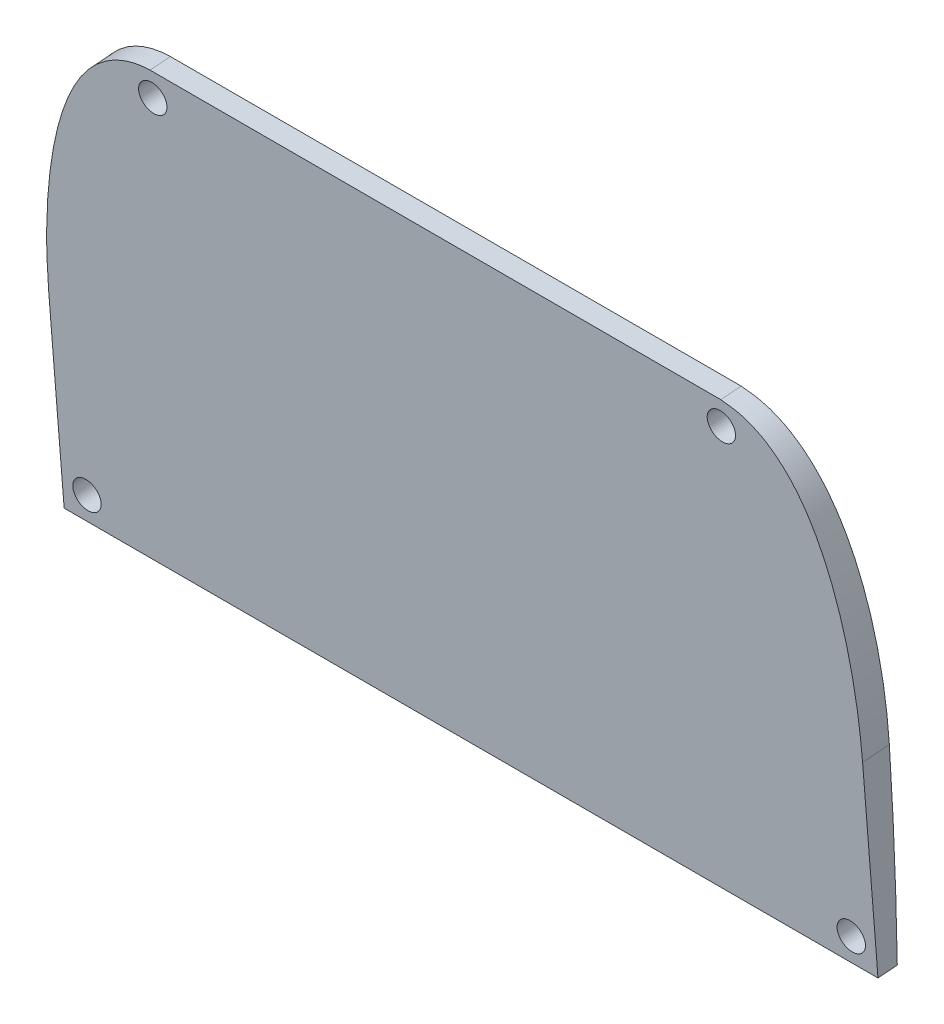
from build123d import *

# Parameters (mm, degrees)
BOSS_EXTRUDE1_DEPTH     = 10
CUT_EXTRUDE1_DEPTH      = 29.7500001
CUT_EXTRUDE1_DEPTH_BACK = 29.7500001
SKETCH3_R               = 1
CUT_EXTRUDE2_DEPTH      = 4.923231052
CUT_EXTRUDE3_DEPTH      = 1.5
CUT_EXTRUDE3_DEPTH_BACK = 1.5


with BuildPart() as part:
    # Sketch1 → Boss-Extrude1 (new body)
    with BuildSketch(Plane(origin=(0, 1.945661651, -24.597655762), x_dir=(-1, 0, 0), z_dir=(0, 0.078853178, -0.99688624))):
        with BuildLine():
            Line((20.118741527, 38.927510312), (-20.205875274, 38.927510312))
            add(Edge.make_bspline(
                [(-20.205875274, 38.927510312), (-20.634098963, 38.892508679), (-21.245835645, 38.778527706), (-21.793411937, 38.641980138), (-22.83466937, 38.198372766), (-23.803353052, 37.478891051), (-24.412556983, 36.884589854), (-24.877490419, 36.344634644), (-25.274800342, 35.805277697), (-25.669505912, 35.18759196), (-25.991077332, 34.611835039), (-26.32458833, 33.935091847), (-26.581827221, 33.349429206), (-26.836336049, 32.707670323), (-27.074080176, 32.039745124), (-27.305049825, 31.313313179), (-27.481649368, 30.696229384), (-27.655403582, 30.02827487), (-27.816800686, 29.340274847), (-27.971090091, 28.607665746), (-28.095711792, 27.948768651), (-28.241597872, 27.08964074), (-28.41706896, 25.841083684), (-28.566039373, 24.442848024), (-28.660522397, 23.195980042), (-28.698123211, 22.438130684), (-28.713170303, 22.033583315), (-28.72027007, 21.807636048), (-28.725707261, 21.608687715), (-28.728334052, 21.498509224), (-28.732226056, 21.320526835), (-28.742152393, 20.794672691), (-28.75, 20.202294151)],
                knots=[0.000338989, 0.000338989, 0.000338989, 0.039386118, 0.055004969, 0.094052098, 0.156527504, 0.203384058, 0.234621761, 0.265859464, 0.297097167, 0.32833487, 0.359572573, 0.390810276, 0.422047979, 0.453285682, 0.484523385, 0.515761088, 0.546998791, 0.578236494, 0.609474197, 0.640711899, 0.671949602, 0.718806157, 0.781281563, 0.843756969, 0.890613523, 0.9140418, 0.925755939, 0.933565364, 0.94137479, 0.949184216, 0.960898355, 0.999945483, 0.999945483, 0.999945483], degree=2))
            Line((-28.75, 20.202294151), (-28.75, 6.427510312))
            Line((-28.75, 6.427510312), (28.75, 6.427510312))
            Line((28.75, 6.427510312), (28.75, 20.202249554))
            add(Edge.make_bspline(
                [(28.75, 20.202249554), (28.742136693, 20.796879453), (28.732153075, 21.324936339), (28.728235159, 21.503651904), (28.725584002, 21.614499101), (28.720117851, 21.813723731), (28.712966508, 22.040249775), (28.697791077, 22.446118641), (28.659754195, 23.208534642), (28.564499372, 24.459675982), (28.41440803, 25.863683892), (28.236422496, 27.123346764), (28.088268606, 27.990052525), (27.961749799, 28.654446766), (27.804153919, 29.396998515), (27.639250072, 30.093405593), (27.461661247, 30.768996368), (27.280351534, 31.39492368), (27.047223746, 32.118771853), (26.806541555, 32.786223535), (26.548675473, 33.427949309), (26.320925204, 33.938978857), (26.120412213, 34.352471329), (25.92443028, 34.732794288), (25.622678502, 35.265443849), (25.234423765, 35.863259987), (24.830722495, 36.402891666), (24.353019395, 36.948050348), (23.75151585, 37.525160308), (22.759896414, 38.235388353), (21.166231977, 38.900698382), (20.118741527, 38.927510312)],
                knots=[5.4217e-05, 5.4217e-05, 5.4217e-05, 0.039105236, 0.050820541, 0.058630745, 0.066440949, 0.074251153, 0.085966458, 0.109397069, 0.156258292, 0.218739922, 0.281221552, 0.328082774, 0.359323589, 0.390564404, 0.421805219, 0.453046034, 0.484286849, 0.515527664, 0.546768479, 0.578009294, 0.609250109, 0.63268072, 0.648301127, 0.671731738, 0.702972553, 0.734213368, 0.765454183, 0.796694998, 0.843556221, 0.90603785, 0.999760295, 0.999760295, 0.999760295], degree=2))
        make_face()
    extrude(amount=BOSS_EXTRUDE1_DEPTH)

    # Sketch2 → Cut-Extrude1 (cut, two sides)
    with BuildSketch(Plane(origin=(0, 0, 0), x_dir=(0, 0, -1), z_dir=(1, 0, 0))) as cut_extrude1_sk:
        with BuildLine():
            add(Edge.make_bspline(
                [(25.5, 3.2), (25.5, 6.804109149), (25.372537051, 14.023285861), (24.790435794, 24.776005778), (23.772909366, 35.484880024), (22.745170912, 42.556468877), (22.107794841, 46.073141759)],
                knots=[0, 0, 0, 0, 0.25, 0.5, 0.75, 1, 1, 1, 1], degree=3))
            Line((22.107794841, 46.073141759), (43.259032881, 46.073141759))
            Line((43.259032881, 46.073141759), (43.259032881, 3.2))
            Line((43.259032881, 3.2), (25.5, 3.2))
        make_face()
    extrude(amount=CUT_EXTRUDE1_DEPTH, mode=Mode.SUBTRACT)
    extrude(cut_extrude1_sk.sketch, amount=-CUT_EXTRUDE1_DEPTH_BACK, mode=Mode.SUBTRACT)

    # Sketch3 → Cut-Extrude2 (cut, through all)
    with BuildSketch(Plane(origin=(0, 1.945661651, -24.597655762), x_dir=(1, 0, 0), z_dir=(0, -0.078853178, 0.99688624))):
        with Locations((-20.062840726, 37.177510312)):
            Circle(SKETCH3_R)
        with Locations((-27, 8.177510312)):
            Circle(SKETCH3_R)
        with Locations((20.109740551, 37.177510312)):
            Circle(SKETCH3_R)
        with Locations((27, 8.177510312)):
            Circle(SKETCH3_R)
    extrude(amount=-CUT_EXTRUDE2_DEPTH, mode=Mode.SUBTRACT)

    # Sketch6 → Cut-Extrude3 (cut, two sides)
    with BuildSketch(Plane(origin=(0, 2.095157837, -26.487632732), x_dir=(1, 0, 0), z_dir=(0, -0.078853178, 0.99688624))) as cut_extrude3_sk:
        with BuildLine():
            Line((7.641783437, 31.566440312), (7.641783437, 31.529400312))
            add(Edge.make_bspline(
                [(7.641783437, 31.529400312), (7.641783437, 23.259600312), (7.641783437, 17.797520312), (0.038703437, 13.797040312)],
                knots=[0.125, 0.125, 0.125, 0.125, 0.25, 0.25, 0.25, 0.25], degree=3))
            Line((0.038703437, 13.797040312), (0.021783437, 13.787520312))
            Line((0.021783437, 13.787520312), (0.004863437, 13.797040312))
            add(Edge.make_bspline(
                [(0.004863437, 13.797040312), (-7.598216563, 17.780600312), (-7.598216563, 23.251120312), (-7.598216563, 31.531520312)],
                knots=[0.5, 0.5, 0.5, 0.5, 0.625, 0.625, 0.625, 0.625], degree=3))
            Line((-7.598216563, 31.531520312), (-7.598216563, 31.568560312))
            Line((-7.598216563, 31.568560312), (7.641783437, 31.566440312))
        make_face()
        with BuildLine():
            Line((-7.028816563, 30.931440312), (-7.028816563, 30.956840312))
            Line((-7.028816563, 30.956840312), (7.091463437, 30.954720312))
            Line((7.091463437, 30.954720312), (7.091463437, 30.929320312))
            add(Edge.make_bspline(
                [(7.091463437, 30.929320312), (7.091463437, 30.702840312), (7.091463437, 30.476360312), (7.092503437, 30.250920312)],
                knots=[0.25, 0.25, 0.25, 0.25, 0.333333333, 0.333333333, 0.333333333, 0.333333333], degree=3))
            add(Edge.make_bspline(
                [(7.092503437, 30.250920312), (7.097783437, 27.110880312), (7.102023437, 24.145400312), (6.220423437, 21.426560312)],
                knots=[0.333333333, 0.333333333, 0.333333333, 0.333333333, 0.416666667, 0.416666667, 0.416666667, 0.416666667], degree=3))
            add(Edge.make_bspline(
                [(6.220423437, 21.426560312), (5.746303437, 19.963960312), (5.059423437, 18.717240312), (4.120703437, 17.614440312)],
                knots=[0.416666667, 0.416666667, 0.416666667, 0.416666667, 0.5, 0.5, 0.5, 0.5], degree=3))
            add(Edge.make_bspline(
                [(4.120703437, 17.614440312), (3.069783437, 16.379360312), (1.730983437, 15.352800312), (0.028143437, 14.476480312)],
                knots=[0.5, 0.5, 0.5, 0.5, 0.583333333, 0.583333333, 0.583333333, 0.583333333], degree=3))
            Line((0.028143437, 14.476480312), (0.016503437, 14.470120312))
            Line((0.016503437, 14.470120312), (0.004863437, 14.476480312))
            add(Edge.make_bspline(
                [(0.004863437, 14.476480312), (-7.042576563, 18.137240312), (-7.036216563, 24.066040312), (-7.028816563, 30.340880312)],
                knots=[0.75, 0.75, 0.75, 0.75, 0.833333333, 0.833333333, 0.833333333, 0.833333333], degree=3))
            add(Edge.make_bspline(
                [(-7.028816563, 30.340880312), (-7.028816563, 30.537760312), (-7.028816563, 30.734600312), (-7.028816563, 30.931440312)],
                knots=[0.833333333, 0.833333333, 0.833333333, 0.833333333, 1, 1, 1, 1], degree=3))
        make_face(mode=Mode.SUBTRACT)
        Polygon((4.152463437, 26.637800312), (-0.047016563, 27.948000312), (-4.263416563, 26.637800312), align=None)
        Polygon((-2.204936563, 27.364880312), (-2.204936563, 28.448600312), (2.069663437, 28.448600312), (2.069663437, 27.375440312), (-0.047016563, 28.035840312), align=None)
        with BuildLine():
            Line((0.480023437, 29.278320312), (-0.586776563, 29.278320312))
            add(Edge.make_bspline(
                [(-0.586776563, 29.278320312), (-0.592056563, 29.644520312), (-0.297856563, 29.923920312), (-0.045976563, 30.147200312)],
                knots=[0.25, 0.25, 0.25, 0.25, 0.5, 0.5, 0.5, 0.5], degree=3))
            add(Edge.make_bspline(
                [(-0.045976563, 30.147200312), (0.202743437, 29.919680312), (0.480023437, 29.655120312), (0.480023437, 29.278320312)],
                knots=[0.5, 0.5, 0.5, 0.5, 1, 1, 1, 1], degree=3))
        make_face()
        with BuildLine():
            Line((-0.565576563, 29.241280312), (0.445103437, 29.241280312))
            add(Edge.make_bspline(
                [(0.445103437, 29.241280312), (0.955223437, 29.126960312), (1.370103437, 28.848640312), (1.569063437, 28.486680312)],
                knots=[0.2, 0.2, 0.2, 0.2, 0.4, 0.4, 0.4, 0.4], degree=3))
            Line((1.569063437, 28.486680312), (-1.689536563, 28.486720312))
            add(Edge.make_bspline(
                [(-1.689536563, 28.486720312), (-1.490576563, 28.848640312), (-1.075696563, 29.128040312), (-0.565576563, 29.241280312)],
                knots=[0.6, 0.6, 0.6, 0.6, 1, 1, 1, 1], degree=3))
        make_face()
        with BuildLine():
            Line((2.483463437, 20.711120312), (2.483463437, 19.465480312))
            add(Edge.make_bspline(
                [(2.483463437, 19.465480312), (2.483463437, 19.370240312), (2.553303437, 19.338480312), (2.643263437, 19.333200312)],
                knots=[0.117647059, 0.117647059, 0.117647059, 0.117647059, 0.176470588, 0.176470588, 0.176470588, 0.176470588], degree=3))
            Line((2.643263437, 19.333200312), (2.846463437, 19.324720312))
            Line((2.846463437, 19.324720312), (2.846463437, 19.219960312))
            add(Edge.make_bspline(
                [(2.846463437, 19.219960312), (2.517303437, 19.223120312), (2.395623437, 19.228440312), (2.274943437, 19.228440312)],
                knots=[0.294117647, 0.294117647, 0.294117647, 0.294117647, 0.352941176, 0.352941176, 0.352941176, 0.352941176], degree=3))
            add(Edge.make_bspline(
                [(2.274943437, 19.228440312), (2.151103437, 19.228440312), (2.032583437, 19.223160312), (1.776463437, 19.219960312)],
                knots=[0.352941176, 0.352941176, 0.352941176, 0.352941176, 0.411764706, 0.411764706, 0.411764706, 0.411764706], degree=3))
            Line((1.776463437, 19.219960312), (1.776463437, 19.324720312))
            Line((1.776463437, 19.324720312), (1.952143437, 19.333200312))
            add(Edge.make_bspline(
                [(1.952143437, 19.333200312), (2.041063437, 19.338480312), (2.111943437, 19.369200312), (2.111943437, 19.465480312)],
                knots=[0.529411765, 0.529411765, 0.529411765, 0.529411765, 0.588235294, 0.588235294, 0.588235294, 0.588235294], degree=3))
            Line((2.111943437, 19.465480312), (2.111943437, 20.371400312))
            add(Edge.make_bspline(
                [(2.111943437, 20.371400312), (2.111943437, 20.707960312), (2.092903437, 20.949240312), (2.083383437, 21.084720312)],
                knots=[0.647058824, 0.647058824, 0.647058824, 0.647058824, 0.705882353, 0.705882353, 0.705882353, 0.705882353], degree=3))
            Line((2.083383437, 21.084720312), (2.118303437, 21.114360312))
            add(Edge.make_bspline(
                [(2.118303437, 21.114360312), (2.360663437, 21.018040312), (2.753303437, 20.878360312), (2.958623437, 20.829680312)],
                knots=[0.764705882, 0.764705882, 0.764705882, 0.764705882, 0.823529412, 0.823529412, 0.823529412, 0.823529412], degree=3))
            add(Edge.make_bspline(
                [(2.958623437, 20.829680312), (2.962863437, 20.770400312), (2.950143437, 20.707960312), (2.919463437, 20.632840312)],
                knots=[0.823529412, 0.823529412, 0.823529412, 0.823529412, 0.882352941, 0.882352941, 0.882352941, 0.882352941], degree=3))
            Line((2.919463437, 20.632840312), (2.525783437, 20.814840312))
            add(Edge.make_bspline(
                [(2.525783437, 20.814840312), (2.481343437, 20.834960312), (2.483463437, 20.770400312), (2.483463437, 20.711120312)],
                knots=[0, 0, 0, 0, 0.058823529, 0.058823529, 0.058823529, 0.058823529], degree=3))
        make_face()
        with BuildLine():
            Line((-0.692576563, 20.711120312), (-0.692576563, 19.465480312))
            add(Edge.make_bspline(
                [(-0.692576563, 19.465480312), (-0.692576563, 19.370240312), (-0.622736563, 19.338480312), (-0.532776563, 19.333200312)],
                knots=[0.117647059, 0.117647059, 0.117647059, 0.117647059, 0.176470588, 0.176470588, 0.176470588, 0.176470588], degree=3))
            Line((-0.532776563, 19.333200312), (-0.329576563, 19.324720312))
            Line((-0.329576563, 19.324720312), (-0.329576563, 19.219960312))
            add(Edge.make_bspline(
                [(-0.329576563, 19.219960312), (-0.658736563, 19.223120312), (-0.780416563, 19.228440312), (-0.901096563, 19.228440312)],
                knots=[0.294117647, 0.294117647, 0.294117647, 0.294117647, 0.352941176, 0.352941176, 0.352941176, 0.352941176], degree=3))
            add(Edge.make_bspline(
                [(-0.901096563, 19.228440312), (-1.024936563, 19.228440312), (-1.143456563, 19.223160312), (-1.400616563, 19.219960312)],
                knots=[0.352941176, 0.352941176, 0.352941176, 0.352941176, 0.411764706, 0.411764706, 0.411764706, 0.411764706], degree=3))
            Line((-1.400616563, 19.219960312), (-1.400616563, 19.324720312))
            Line((-1.400616563, 19.324720312), (-1.224936563, 19.333200312))
            add(Edge.make_bspline(
                [(-1.224936563, 19.333200312), (-1.134976563, 19.338480312), (-1.065136563, 19.369200312), (-1.065136563, 19.465480312)],
                knots=[0.529411765, 0.529411765, 0.529411765, 0.529411765, 0.588235294, 0.588235294, 0.588235294, 0.588235294], degree=3))
            Line((-1.065136563, 19.465480312), (-1.065136563, 20.371400312))
            add(Edge.make_bspline(
                [(-1.065136563, 20.371400312), (-1.065136563, 20.707960312), (-1.084176563, 20.949240312), (-1.092656563, 21.084720312)],
                knots=[0.647058824, 0.647058824, 0.647058824, 0.647058824, 0.705882353, 0.705882353, 0.705882353, 0.705882353], degree=3))
            Line((-1.092656563, 21.084720312), (-1.058776563, 21.114360312))
            add(Edge.make_bspline(
                [(-1.058776563, 21.114360312), (-0.817456563, 21.018040312), (-0.423776563, 20.878360312), (-0.217416563, 20.829680312)],
                knots=[0.764705882, 0.764705882, 0.764705882, 0.764705882, 0.823529412, 0.823529412, 0.823529412, 0.823529412], degree=3))
            add(Edge.make_bspline(
                [(-0.217416563, 20.829680312), (-0.215296563, 20.770400312), (-0.225896563, 20.707960312), (-0.257616563, 20.632840312)],
                knots=[0.823529412, 0.823529412, 0.823529412, 0.823529412, 0.882352941, 0.882352941, 0.882352941, 0.882352941], degree=3))
            Line((-0.257616563, 20.632840312), (-0.650256563, 20.814840312))
            add(Edge.make_bspline(
                [(-0.650256563, 20.814840312), (-0.694696563, 20.834960312), (-0.692576563, 20.770400312), (-0.692576563, 20.711120312)],
                knots=[0, 0, 0, 0, 0.058823529, 0.058823529, 0.058823529, 0.058823529], degree=3))
        make_face()
        with BuildLine():
            Line((-2.176376563, 20.711120312), (-2.176376563, 19.465480312))
            add(Edge.make_bspline(
                [(-2.176376563, 19.465480312), (-2.176376563, 19.370240312), (-2.106536563, 19.338480312), (-2.016576563, 19.333200312)],
                knots=[0.117647059, 0.117647059, 0.117647059, 0.117647059, 0.176470588, 0.176470588, 0.176470588, 0.176470588], degree=3))
            Line((-2.016576563, 19.333200312), (-1.814416563, 19.324720312))
            Line((-1.814416563, 19.324720312), (-1.814416563, 19.219960312))
            add(Edge.make_bspline(
                [(-1.814416563, 19.219960312), (-2.143576563, 19.223120312), (-2.265256563, 19.228440312), (-2.384856563, 19.228440312)],
                knots=[0.294117647, 0.294117647, 0.294117647, 0.294117647, 0.352941176, 0.352941176, 0.352941176, 0.352941176], degree=3))
            add(Edge.make_bspline(
                [(-2.384856563, 19.228440312), (-2.508696563, 19.228440312), (-2.627216563, 19.223160312), (-2.884376563, 19.219960312)],
                knots=[0.352941176, 0.352941176, 0.352941176, 0.352941176, 0.411764706, 0.411764706, 0.411764706, 0.411764706], degree=3))
            Line((-2.884376563, 19.219960312), (-2.884376563, 19.324720312))
            Line((-2.884376563, 19.324720312), (-2.708696563, 19.333200312))
            add(Edge.make_bspline(
                [(-2.708696563, 19.333200312), (-2.618736563, 19.338480312), (-2.547816563, 19.369200312), (-2.547816563, 19.465480312)],
                knots=[0.529411765, 0.529411765, 0.529411765, 0.529411765, 0.588235294, 0.588235294, 0.588235294, 0.588235294], degree=3))
            Line((-2.547816563, 19.465480312), (-2.547816563, 20.371400312))
            add(Edge.make_bspline(
                [(-2.547816563, 20.371400312), (-2.547816563, 20.707960312), (-2.566856563, 20.949240312), (-2.576376563, 21.084720312)],
                knots=[0.647058824, 0.647058824, 0.647058824, 0.647058824, 0.705882353, 0.705882353, 0.705882353, 0.705882353], degree=3))
            Line((-2.576376563, 21.084720312), (-2.542496563, 21.114360312))
            add(Edge.make_bspline(
                [(-2.542496563, 21.114360312), (-2.301176563, 21.018040312), (-1.907496563, 20.878360312), (-1.701136563, 20.829680312)],
                knots=[0.764705882, 0.764705882, 0.764705882, 0.764705882, 0.823529412, 0.823529412, 0.823529412, 0.823529412], degree=3))
            add(Edge.make_bspline(
                [(-1.701136563, 20.829680312), (-1.697976563, 20.770400312), (-1.709616563, 20.707960312), (-1.741336563, 20.632840312)],
                knots=[0.823529412, 0.823529412, 0.823529412, 0.823529412, 0.882352941, 0.882352941, 0.882352941, 0.882352941], degree=3))
            Line((-1.741336563, 20.632840312), (-2.134056563, 20.814840312))
            add(Edge.make_bspline(
                [(-2.134056563, 20.814840312), (-2.178496563, 20.834960312), (-2.176376563, 20.770400312), (-2.176376563, 20.711120312)],
                knots=[0, 0, 0, 0, 0.058823529, 0.058823529, 0.058823529, 0.058823529], degree=3))
        make_face()
        with BuildLine():
            Line((-0.586776563, 23.892440312), (-0.564536563, 23.892440312))
            Line((-0.564536563, 23.892440312), (-0.564536563, 23.673360312))
            Line((-0.564536563, 23.673360312), (-0.812176563, 23.663840312))
            add(Edge.make_bspline(
                [(-0.812176563, 23.663840312), (-0.958216563, 23.658560312), (-1.036536563, 23.634200312), (-1.036536563, 23.525200312)],
                knots=[0.21875, 0.21875, 0.21875, 0.21875, 0.25, 0.25, 0.25, 0.25], degree=3))
            Line((-1.036536563, 23.525200312), (-1.036536563, 22.972760312))
            add(Edge.make_bspline(
                [(-1.036536563, 22.972760312), (-0.851336563, 22.903960312), (-0.684096563, 22.871160312), (-0.511616563, 22.871160312)],
                knots=[0.28125, 0.28125, 0.28125, 0.28125, 0.3125, 0.3125, 0.3125, 0.3125], degree=3))
            add(Edge.make_bspline(
                [(-0.511616563, 22.871160312), (0.326583437, 22.871160312), (0.623983437, 23.610920312), (0.623983437, 24.244880312)],
                knots=[0.3125, 0.3125, 0.3125, 0.3125, 0.34375, 0.34375, 0.34375, 0.34375], degree=3))
            add(Edge.make_bspline(
                [(0.623983437, 24.244880312), (0.623983437, 24.964560312), (0.213343437, 25.411160312), (-0.448096563, 25.411160312)],
                knots=[0.34375, 0.34375, 0.34375, 0.34375, 0.375, 0.375, 0.375, 0.375], degree=3))
            add(Edge.make_bspline(
                [(-0.448096563, 25.411160312), (-0.834376563, 25.411160312), (-1.179416563, 25.300040312), (-1.331816563, 25.126480312)],
                knots=[0.375, 0.375, 0.375, 0.375, 0.40625, 0.40625, 0.40625, 0.40625], degree=3))
            Line((-1.331816563, 25.126480312), (-1.352976563, 24.764520312))
            Line((-1.352976563, 24.764520312), (-1.354056563, 24.745480312))
            Line((-1.354056563, 24.745480312), (-1.560416563, 24.745480312))
            Line((-1.560416563, 24.745480312), (-1.569936563, 24.831200312))
            add(Edge.make_bspline(
                [(-1.569936563, 24.831200312), (-1.592176563, 25.021720312), (-1.623896563, 25.283120312), (-1.660936563, 25.419640312)],
                knots=[0.53125, 0.53125, 0.53125, 0.53125, 0.5625, 0.5625, 0.5625, 0.5625], degree=3))
            Line((-1.660936563, 25.419640312), (-1.664096563, 25.428120312))
            Line((-1.664096563, 25.428120312), (-1.630216563, 25.488440312))
            Line((-1.630216563, 25.488440312), (-1.623856563, 25.491600312))
            add(Edge.make_bspline(
                [(-1.623856563, 25.491600312), (-1.186776563, 25.671520312), (-0.776136563, 25.695840312), (-0.432176563, 25.695840312)],
                knots=[0.65625, 0.65625, 0.65625, 0.65625, 0.6875, 0.6875, 0.6875, 0.6875], degree=3))
            add(Edge.make_bspline(
                [(-0.432176563, 25.695840312), (0.435663437, 25.695840312), (1.311943437, 25.230160312), (1.311943437, 24.189840312)],
                knots=[0.6875, 0.6875, 0.6875, 0.6875, 0.71875, 0.71875, 0.71875, 0.71875], degree=3))
            add(Edge.make_bspline(
                [(1.311943437, 24.189840312), (1.311943437, 23.202400312), (0.650503437, 22.588600312), (-0.414216563, 22.588600312)],
                knots=[0.71875, 0.71875, 0.71875, 0.71875, 0.75, 0.75, 0.75, 0.75], degree=3))
            add(Edge.make_bspline(
                [(-0.414216563, 22.588600312), (-0.816376563, 22.588600312), (-1.230176563, 22.673280312), (-1.678936563, 22.846840312)],
                knots=[0.75, 0.75, 0.75, 0.75, 0.78125, 0.78125, 0.78125, 0.78125], degree=3))
            Line((-1.678936563, 22.846840312), (-1.692696563, 22.852120312))
            Line((-1.692696563, 22.852120312), (-1.692696563, 23.569680312))
            add(Edge.make_bspline(
                [(-1.692696563, 23.569680312), (-1.692696563, 23.657520312), (-1.744536563, 23.672320312), (-1.895896563, 23.703040312)],
                knots=[0.84375, 0.84375, 0.84375, 0.84375, 0.875, 0.875, 0.875, 0.875], degree=3))
            Line((-1.895896563, 23.703040312), (-1.912816563, 23.706200312))
            Line((-1.912816563, 23.706200312), (-1.912816563, 23.892480312))
            Line((-1.912816563, 23.892480312), (-1.891696563, 23.891400312))
            add(Edge.make_bspline(
                [(-1.891696563, 23.891400312), (-1.831376563, 23.890360312), (-1.767856563, 23.888240312), (-1.702256563, 23.887160312)],
                knots=[0, 0, 0, 0, 0.03125, 0.03125, 0.03125, 0.03125], degree=3))
            add(Edge.make_bspline(
                [(-1.702256563, 23.887160312), (-1.539256563, 23.882920312), (-1.368896563, 23.878680312), (-1.218616563, 23.878680312)],
                knots=[0.03125, 0.03125, 0.03125, 0.03125, 0.0625, 0.0625, 0.0625, 0.0625], degree=3))
            add(Edge.make_bspline(
                [(-1.218616563, 23.878680312), (-1.089496563, 23.878680312), (-0.957216563, 23.881840312), (-0.829136563, 23.886080312)],
                knots=[0.0625, 0.0625, 0.0625, 0.0625, 0.09375, 0.09375, 0.09375, 0.09375], degree=3))
            add(Edge.make_bspline(
                [(-0.829136563, 23.886080312), (-0.748696563, 23.888200312), (-0.667216563, 23.890320312), (-0.586776563, 23.892440312)],
                knots=[0.09375, 0.09375, 0.09375, 0.09375, 0.125, 0.125, 0.125, 0.125], degree=3))
        make_face()
        with BuildLine():
            Line((1.667503437, 25.420720312), (1.488663437, 25.435520312))
            Line((1.488663437, 25.435520312), (1.488663437, 25.636600312))
            Line((1.488663437, 25.636600312), (1.510903437, 25.636600312))
            add(Edge.make_bspline(
                [(1.510903437, 25.636600312), (1.600863437, 25.634480312), (1.680223437, 25.632360312), (1.752223437, 25.629200312)],
                knots=[0.060606061, 0.060606061, 0.060606061, 0.060606061, 0.075757576, 0.075757576, 0.075757576, 0.075757576], degree=3))
            add(Edge.make_bspline(
                [(1.752223437, 25.629200312), (1.850663437, 25.626040312), (1.936383437, 25.622840312), (2.010463437, 25.622840312)],
                knots=[0.075757576, 0.075757576, 0.075757576, 0.075757576, 0.090909091, 0.090909091, 0.090909091, 0.090909091], degree=3))
            add(Edge.make_bspline(
                [(2.010463437, 25.622840312), (2.083503437, 25.622840312), (2.170263437, 25.626000312), (2.269743437, 25.629200312)],
                knots=[0.090909091, 0.090909091, 0.090909091, 0.090909091, 0.106060606, 0.106060606, 0.106060606, 0.106060606], degree=3))
            add(Edge.make_bspline(
                [(2.269743437, 25.629200312), (2.340663437, 25.631320312), (2.417903437, 25.634480312), (2.504703437, 25.635560312)],
                knots=[0.106060606, 0.106060606, 0.106060606, 0.106060606, 0.121212121, 0.121212121, 0.121212121, 0.121212121], degree=3))
            Line((2.504703437, 25.635560312), (2.519503437, 25.635560312))
            Line((2.519503437, 25.635560312), (2.524783437, 25.621800312))
            add(Edge.make_bspline(
                [(2.524783437, 25.621800312), (2.543823437, 25.578400312), (2.562903437, 25.532880312), (2.581943437, 25.485280312)],
                knots=[0.151515152, 0.151515152, 0.151515152, 0.151515152, 0.166666667, 0.166666667, 0.166666667, 0.166666667], degree=3))
            add(Edge.make_bspline(
                [(2.581943437, 25.485280312), (2.630623437, 25.368880312), (2.680383437, 25.248200312), (2.735383437, 25.136040312)],
                knots=[0.166666667, 0.166666667, 0.166666667, 0.166666667, 0.181818182, 0.181818182, 0.181818182, 0.181818182], degree=3))
            Line((2.735383437, 25.136040312), (3.504783437, 23.548520312))
            Line((3.504783437, 23.548520312), (4.165183437, 24.928600312))
            add(Edge.make_bspline(
                [(4.165183437, 24.928600312), (4.195863437, 24.994200312), (4.232903437, 25.073600312), (4.273143437, 25.157200312)],
                knots=[0.212121212, 0.212121212, 0.212121212, 0.212121212, 0.227272727, 0.227272727, 0.227272727, 0.227272727], degree=3))
            add(Edge.make_bspline(
                [(4.273143437, 25.157200312), (4.350383437, 25.320200312), (4.437183437, 25.505400312), (4.489063437, 25.621800312)],
                knots=[0.227272727, 0.227272727, 0.227272727, 0.227272727, 0.242424242, 0.242424242, 0.242424242, 0.242424242], degree=3))
            Line((4.489063437, 25.621800312), (4.495423437, 25.635560312))
            Line((4.495423437, 25.635560312), (4.509183437, 25.635560312))
            add(Edge.make_bspline(
                [(4.509183437, 25.635560312), (4.556823437, 25.634520312), (4.604423437, 25.632400312), (4.653103437, 25.631320312)],
                knots=[0.272727273, 0.272727273, 0.272727273, 0.272727273, 0.287878788, 0.287878788, 0.287878788, 0.287878788], degree=3))
            add(Edge.make_bspline(
                [(4.653103437, 25.631320312), (4.895463437, 25.622840312), (5.151583437, 25.621800312), (5.397103437, 25.631320312)],
                knots=[0.287878788, 0.287878788, 0.287878788, 0.287878788, 0.303030303, 0.303030303, 0.303030303, 0.303030303], degree=3))
            add(Edge.make_bspline(
                [(5.397103437, 25.631320312), (5.445783437, 25.632360312), (5.493423437, 25.634480312), (5.542103437, 25.635560312)],
                knots=[0.303030303, 0.303030303, 0.303030303, 0.303030303, 0.318181818, 0.318181818, 0.318181818, 0.318181818], degree=3))
            Line((5.542103437, 25.635560312), (5.564343437, 25.635560312))
            Line((5.564343437, 25.635560312), (5.564343437, 25.434480312))
            Line((5.564343437, 25.434480312), (5.385503437, 25.419680312))
            add(Edge.make_bspline(
                [(5.385503437, 25.419680312), (5.274383437, 25.411200312), (5.242623437, 25.390040312), (5.225703437, 25.359360312)],
                knots=[0.363636364, 0.363636364, 0.363636364, 0.363636364, 0.378787879, 0.378787879, 0.378787879, 0.378787879], degree=3))
            add(Edge.make_bspline(
                [(5.225703437, 25.359360312), (5.203463437, 25.310680312), (5.198183437, 25.198480312), (5.198183437, 25.019640312)],
                knots=[0.378787879, 0.378787879, 0.378787879, 0.378787879, 0.393939394, 0.393939394, 0.393939394, 0.393939394], degree=3))
            Line((5.198183437, 25.019640312), (5.198183437, 23.262800312))
            add(Edge.make_bspline(
                [(5.198183437, 23.262800312), (5.198183437, 23.088160312), (5.202423437, 22.970680312), (5.225703437, 22.925200312)],
                knots=[0.409090909, 0.409090909, 0.409090909, 0.409090909, 0.424242424, 0.424242424, 0.424242424, 0.424242424], degree=3))
            add(Edge.make_bspline(
                [(5.225703437, 22.925200312), (5.242623437, 22.892400312), (5.274383437, 22.871240312), (5.385503437, 22.862760312)],
                knots=[0.424242424, 0.424242424, 0.424242424, 0.424242424, 0.439393939, 0.439393939, 0.439393939, 0.439393939], degree=3))
            Line((5.385503437, 22.862760312), (5.564343437, 22.847960312))
            Line((5.564343437, 22.847960312), (5.564343437, 22.646880312))
            Line((5.564343437, 22.646880312), (5.542103437, 22.646880312))
            add(Edge.make_bspline(
                [(5.542103437, 22.646880312), (5.490263437, 22.647920312), (5.437343437, 22.650040312), (5.384423437, 22.652160312)],
                knots=[0.484848485, 0.484848485, 0.484848485, 0.484848485, 0.5, 0.5, 0.5, 0.5], degree=3))
            add(Edge.make_bspline(
                [(5.384423437, 22.652160312), (5.273303437, 22.656400312), (5.158983437, 22.660640312), (5.047863437, 22.660640312)],
                knots=[0.5, 0.5, 0.5, 0.5, 0.515151515, 0.515151515, 0.515151515, 0.515151515], degree=3))
            add(Edge.make_bspline(
                [(5.047863437, 22.660640312), (4.936743437, 22.660640312), (4.824543437, 22.656400312), (4.715543437, 22.652160312)],
                knots=[0.515151515, 0.515151515, 0.515151515, 0.515151515, 0.53030303, 0.53030303, 0.53030303, 0.53030303], degree=3))
            add(Edge.make_bspline(
                [(4.715543437, 22.652160312), (4.662623437, 22.650040312), (4.609703437, 22.647920312), (4.556783437, 22.646880312)],
                knots=[0.53030303, 0.53030303, 0.53030303, 0.53030303, 0.545454545, 0.545454545, 0.545454545, 0.545454545], degree=3))
            Line((4.556783437, 22.646880312), (4.534543437, 22.646880312))
            Line((4.534543437, 22.646880312), (4.534543437, 22.847960312))
            Line((4.534543437, 22.847960312), (4.714463437, 22.862760312))
            add(Edge.make_bspline(
                [(4.714463437, 22.862760312), (4.824543437, 22.871240312), (4.857343437, 22.892400312), (4.874263437, 22.924160312)],
                knots=[0.590909091, 0.590909091, 0.590909091, 0.590909091, 0.606060606, 0.606060606, 0.606060606, 0.606060606], degree=3))
            add(Edge.make_bspline(
                [(4.874263437, 22.924160312), (4.897543437, 22.970720312), (4.901783437, 23.088200312), (4.901783437, 23.262840312)],
                knots=[0.606060606, 0.606060606, 0.606060606, 0.606060606, 0.621212121, 0.621212121, 0.621212121, 0.621212121], degree=3))
            Line((4.901783437, 23.262840312), (4.901743437, 24.965640312))
            Line((4.901743437, 24.965640312), (3.952423437, 22.987600312))
            Line((3.952423437, 22.987600312), (3.935503437, 22.951600312))
            add(Edge.make_bspline(
                [(3.935503437, 22.951600312), (3.884703437, 22.842600312), (3.837063437, 22.739920312), (3.798983437, 22.632000312)],
                knots=[0.666666667, 0.666666667, 0.666666667, 0.666666667, 0.681818182, 0.681818182, 0.681818182, 0.681818182], degree=3))
            Line((3.798983437, 22.632000312), (3.793703437, 22.618240312))
            Line((3.793703437, 22.618240312), (3.616943437, 22.618240312))
            Line((3.616943437, 22.618240312), (3.611663437, 22.632000312))
            add(Edge.make_bspline(
                [(3.611663437, 22.632000312), (3.554503437, 22.775920312), (3.469863437, 22.962200312), (3.354503437, 23.200320312)],
                knots=[0.727272727, 0.727272727, 0.727272727, 0.727272727, 0.742424242, 0.742424242, 0.742424242, 0.742424242], degree=3))
            Line((3.354503437, 23.200320312), (2.507823437, 24.962440312))
            Line((2.507823437, 24.962440312), (2.507823437, 23.264880312))
            add(Edge.make_bspline(
                [(2.507823437, 23.264880312), (2.507823437, 23.090240312), (2.512063437, 22.972760312), (2.535343437, 22.927280312)],
                knots=[0.772727273, 0.772727273, 0.772727273, 0.772727273, 0.787878788, 0.787878788, 0.787878788, 0.787878788], degree=3))
            add(Edge.make_bspline(
                [(2.535343437, 22.927280312), (2.549103437, 22.899760312), (2.595663437, 22.884960312), (2.694103437, 22.878600312)],
                knots=[0.787878788, 0.787878788, 0.787878788, 0.787878788, 0.803030303, 0.803030303, 0.803030303, 0.803030303], degree=3))
            Line((2.694103437, 22.878600312), (2.872943437, 22.863800312))
            Line((2.872943437, 22.863800312), (2.872943437, 22.650000312))
            Line((2.872943437, 22.650000312), (2.735343437, 22.653160312))
            add(Edge.make_bspline(
                [(2.735343437, 22.653160312), (2.578703437, 22.657400312), (2.385023437, 22.662680312), (2.179703437, 22.662680312)],
                knots=[0.848484848, 0.848484848, 0.848484848, 0.848484848, 0.863636364, 0.863636364, 0.863636364, 0.863636364], degree=3))
            add(Edge.make_bspline(
                [(2.179703437, 22.662680312), (1.979663437, 22.662680312), (1.785983437, 22.657400312), (1.630423437, 22.653160312)],
                knots=[0.863636364, 0.863636364, 0.863636364, 0.863636364, 0.878787879, 0.878787879, 0.878787879, 0.878787879], degree=3))
            Line((1.630423437, 22.653160312), (1.489663437, 22.650000312))
            Line((1.489663437, 22.650000312), (1.489663437, 22.863800312))
            Line((1.489663437, 22.863800312), (1.669583437, 22.878600312))
            add(Edge.make_bspline(
                [(1.669583437, 22.878600312), (1.768023437, 22.886000312), (1.814583437, 22.900840312), (1.829383437, 22.927280312)],
                knots=[0.924242424, 0.924242424, 0.924242424, 0.924242424, 0.939393939, 0.939393939, 0.939393939, 0.939393939], degree=3))
            add(Edge.make_bspline(
                [(1.829383437, 22.927280312), (1.852663437, 22.973840312), (1.856903437, 23.091320312), (1.856903437, 23.265960312)],
                knots=[0.939393939, 0.939393939, 0.939393939, 0.939393939, 0.954545455, 0.954545455, 0.954545455, 0.954545455], degree=3))
            Line((1.856903437, 23.265960312), (1.856903437, 25.022800312))
            add(Edge.make_bspline(
                [(1.856903437, 25.022800312), (1.854823437, 25.198480312), (1.850583437, 25.311720312), (1.827303437, 25.359320312)],
                knots=[0.96969697, 0.96969697, 0.96969697, 0.96969697, 1, 1, 1, 1], degree=3))
            add(Edge.make_bspline(
                [(1.827303437, 25.359320312), (1.811423437, 25.391080312), (1.779663437, 25.411160312), (1.667503437, 25.420720312)],
                knots=[0, 0, 0, 0, 0.015151515, 0.015151515, 0.015151515, 0.015151515], degree=3))
        make_face()
        with BuildLine():
            Line((-5.328096563, 25.408000312), (-5.509056563, 25.422800312))
            Line((-5.509056563, 25.422800312), (-5.509056563, 25.635520312))
            Line((-5.509056563, 25.635520312), (-5.486816563, 25.635520312))
            add(Edge.make_bspline(
                [(-5.486816563, 25.635520312), (-5.438136563, 25.634480312), (-5.385216563, 25.633400312), (-5.328056563, 25.632360312)],
                knots=[0.061538462, 0.061538462, 0.061538462, 0.061538462, 0.076923077, 0.076923077, 0.076923077, 0.076923077], degree=3))
            add(Edge.make_bspline(
                [(-5.328056563, 25.632360312), (-5.174616563, 25.628120312), (-4.998896563, 25.623880312), (-4.812656563, 25.623880312)],
                knots=[0.076923077, 0.076923077, 0.076923077, 0.076923077, 0.092307692, 0.092307692, 0.092307692, 0.092307692], degree=3))
            add(Edge.make_bspline(
                [(-4.812656563, 25.623880312), (-4.623216563, 25.623880312), (-4.448576563, 25.628120312), (-4.293016563, 25.632360312)],
                knots=[0.092307692, 0.092307692, 0.092307692, 0.092307692, 0.107692308, 0.107692308, 0.107692308, 0.107692308], degree=3))
            add(Edge.make_bspline(
                [(-4.293016563, 25.632360312), (-4.235856563, 25.633400312), (-4.182936563, 25.635520312), (-4.135336563, 25.635520312)],
                knots=[0.107692308, 0.107692308, 0.107692308, 0.107692308, 0.123076923, 0.123076923, 0.123076923, 0.123076923], degree=3))
            Line((-4.135336563, 25.635520312), (-4.113096563, 25.635520312))
            Line((-4.113096563, 25.635520312), (-4.113096563, 25.422800312))
            Line((-4.113096563, 25.422800312), (-4.293016563, 25.408000312))
            add(Edge.make_bspline(
                [(-4.293016563, 25.408000312), (-4.392496563, 25.400600312), (-4.440136563, 25.385760312), (-4.453896563, 25.359320312)],
                knots=[0.169230769, 0.169230769, 0.169230769, 0.169230769, 0.184615385, 0.184615385, 0.184615385, 0.184615385], degree=3))
            add(Edge.make_bspline(
                [(-4.453896563, 25.359320312), (-4.479296563, 25.308520312), (-4.481416563, 25.169880312), (-4.481416563, 25.019600312)],
                knots=[0.184615385, 0.184615385, 0.184615385, 0.184615385, 0.2, 0.2, 0.2, 0.2], degree=3))
            Line((-4.481416563, 25.019600312), (-4.481416563, 24.359200312))
            add(Edge.make_bspline(
                [(-4.481416563, 24.359200312), (-4.418976563, 24.356040312), (-4.334296563, 24.351800312), (-4.151216563, 24.351800312)],
                knots=[0.215384615, 0.215384615, 0.215384615, 0.215384615, 0.230769231, 0.230769231, 0.230769231, 0.230769231], degree=3))
            Line((-4.151216563, 24.351800312), (-3.515176563, 24.351800312))
            add(Edge.make_bspline(
                [(-3.515176563, 24.351800312), (-3.332096563, 24.351800312), (-3.247416563, 24.356040312), (-3.184976563, 24.359200312)],
                knots=[0.246153846, 0.246153846, 0.246153846, 0.246153846, 0.261538462, 0.261538462, 0.261538462, 0.261538462], degree=3))
            Line((-3.184976563, 24.359200312), (-3.184976563, 25.019600312))
            add(Edge.make_bspline(
                [(-3.184976563, 25.019600312), (-3.184976563, 25.176240312), (-3.187096563, 25.309600312), (-3.212496563, 25.359320312)],
                knots=[0.276923077, 0.276923077, 0.276923077, 0.276923077, 0.292307692, 0.292307692, 0.292307692, 0.292307692], degree=3))
            add(Edge.make_bspline(
                [(-3.212496563, 25.359320312), (-3.226256563, 25.385760312), (-3.273896563, 25.400600312), (-3.374416563, 25.408000312)],
                knots=[0.292307692, 0.292307692, 0.292307692, 0.292307692, 0.307692308, 0.307692308, 0.307692308, 0.307692308], degree=3))
            Line((-3.374416563, 25.408000312), (-3.554336563, 25.422800312))
            Line((-3.554336563, 25.422800312), (-3.554336563, 25.635520312))
            Line((-3.554336563, 25.635520312), (-3.532096563, 25.635520312))
            add(Edge.make_bspline(
                [(-3.532096563, 25.635520312), (-3.483416563, 25.634480312), (-3.429456563, 25.633400312), (-3.372296563, 25.632360312)],
                knots=[0.353846154, 0.353846154, 0.353846154, 0.353846154, 0.369230769, 0.369230769, 0.369230769, 0.369230769], degree=3))
            add(Edge.make_bspline(
                [(-3.372296563, 25.632360312), (-3.218856563, 25.628120312), (-3.044216563, 25.623880312), (-2.860056563, 25.623880312)],
                knots=[0.369230769, 0.369230769, 0.369230769, 0.369230769, 0.384615385, 0.384615385, 0.384615385, 0.384615385], degree=3))
            add(Edge.make_bspline(
                [(-2.860056563, 25.623880312), (-2.670616563, 25.623880312), (-2.493856563, 25.628120312), (-2.339336563, 25.632360312)],
                knots=[0.384615385, 0.384615385, 0.384615385, 0.384615385, 0.4, 0.4, 0.4, 0.4], degree=3))
            add(Edge.make_bspline(
                [(-2.339336563, 25.632360312), (-2.283256563, 25.633400312), (-2.230336563, 25.635520312), (-2.181656563, 25.635520312)],
                knots=[0.4, 0.4, 0.4, 0.4, 0.415384615, 0.415384615, 0.415384615, 0.415384615], degree=3))
            Line((-2.181656563, 25.635520312), (-2.159416563, 25.635520312))
            Line((-2.159416563, 25.635520312), (-2.159416563, 25.422800312))
            Line((-2.159416563, 25.422800312), (-2.340376563, 25.408000312))
            add(Edge.make_bspline(
                [(-2.340376563, 25.408000312), (-2.438816563, 25.400600312), (-2.487496563, 25.385760312), (-2.500176563, 25.359320312)],
                knots=[0.461538462, 0.461538462, 0.461538462, 0.461538462, 0.476923077, 0.476923077, 0.476923077, 0.476923077], degree=3))
            add(Edge.make_bspline(
                [(-2.500176563, 25.359320312), (-2.525576563, 25.310640312), (-2.527696563, 25.176240312), (-2.527696563, 25.020640312)],
                knots=[0.476923077, 0.476923077, 0.476923077, 0.476923077, 0.492307692, 0.492307692, 0.492307692, 0.492307692], degree=3))
            Line((-2.527696563, 25.020640312), (-2.527696563, 23.263800312))
            add(Edge.make_bspline(
                [(-2.527696563, 23.263800312), (-2.527696563, 23.107160312), (-2.525576563, 22.974880312), (-2.500176563, 22.924080312)],
                knots=[0.507692308, 0.507692308, 0.507692308, 0.507692308, 0.523076923, 0.523076923, 0.523076923, 0.523076923], degree=3))
            add(Edge.make_bspline(
                [(-2.500176563, 22.924080312), (-2.486416563, 22.896560312), (-2.440896563, 22.882800312), (-2.339296563, 22.874320312)],
                knots=[0.523076923, 0.523076923, 0.523076923, 0.523076923, 0.538461538, 0.538461538, 0.538461538, 0.538461538], degree=3))
            Line((-2.339296563, 22.874320312), (-2.158336563, 22.860560312))
            Line((-2.158336563, 22.860560312), (-2.158336563, 22.645720312))
            Line((-2.158336563, 22.645720312), (-2.255696563, 22.648880312))
            add(Edge.make_bspline(
                [(-2.255696563, 22.648880312), (-2.423976563, 22.653120312), (-2.632456563, 22.659480312), (-2.857896563, 22.659480312)],
                knots=[0.584615385, 0.584615385, 0.584615385, 0.584615385, 0.6, 0.6, 0.6, 0.6], degree=3))
            add(Edge.make_bspline(
                [(-2.857896563, 22.659480312), (-3.076976563, 22.659480312), (-3.285456563, 22.653120312), (-3.452696563, 22.648880312)],
                knots=[0.6, 0.6, 0.6, 0.6, 0.615384615, 0.615384615, 0.615384615, 0.615384615], degree=3))
            Line((-3.452696563, 22.648880312), (-3.553256563, 22.645720312))
            Line((-3.553256563, 22.645720312), (-3.553256563, 22.860560312))
            Line((-3.553256563, 22.860560312), (-3.373336563, 22.874320312))
            add(Edge.make_bspline(
                [(-3.373336563, 22.874320312), (-3.271736563, 22.882800312), (-3.225176563, 22.896560312), (-3.211416563, 22.924080312)],
                knots=[0.661538462, 0.661538462, 0.661538462, 0.661538462, 0.676923077, 0.676923077, 0.676923077, 0.676923077], degree=3))
            add(Edge.make_bspline(
                [(-3.211416563, 22.924080312), (-3.186016563, 22.973840312), (-3.183896563, 23.107160312), (-3.183896563, 23.263800312)],
                knots=[0.676923077, 0.676923077, 0.676923077, 0.676923077, 0.692307692, 0.692307692, 0.692307692, 0.692307692], degree=3))
            Line((-3.183896563, 23.263800312), (-3.183896563, 24.061800312))
            add(Edge.make_bspline(
                [(-3.183896563, 24.061800312), (-3.246336563, 24.066040312), (-3.331016563, 24.069200312), (-3.514096563, 24.069200312)],
                knots=[0.707692308, 0.707692308, 0.707692308, 0.707692308, 0.723076923, 0.723076923, 0.723076923, 0.723076923], degree=3))
            Line((-3.514096563, 24.069200312), (-4.150176563, 24.069200312))
            add(Edge.make_bspline(
                [(-4.150176563, 24.069200312), (-4.333256563, 24.069200312), (-4.417936563, 24.066040312), (-4.480376563, 24.061800312)],
                knots=[0.738461538, 0.738461538, 0.738461538, 0.738461538, 0.753846154, 0.753846154, 0.753846154, 0.753846154], degree=3))
            Line((-4.480376563, 24.061800312), (-4.480376563, 23.263800312))
            add(Edge.make_bspline(
                [(-4.480376563, 23.263800312), (-4.480376563, 23.113520312), (-4.478256563, 22.975920312), (-4.452856563, 22.924080312)],
                knots=[0.769230769, 0.769230769, 0.769230769, 0.769230769, 0.784615385, 0.784615385, 0.784615385, 0.784615385], degree=3))
            add(Edge.make_bspline(
                [(-4.452856563, 22.924080312), (-4.439096563, 22.896560312), (-4.392536563, 22.882800312), (-4.290936563, 22.874320312)],
                knots=[0.784615385, 0.784615385, 0.784615385, 0.784615385, 0.8, 0.8, 0.8, 0.8], degree=3))
            Line((-4.290936563, 22.874320312), (-4.111016563, 22.860560312))
            Line((-4.111016563, 22.860560312), (-4.111016563, 22.645720312))
            Line((-4.111016563, 22.645720312), (-4.209456563, 22.648880312))
            add(Edge.make_bspline(
                [(-4.209456563, 22.648880312), (-4.376656563, 22.654160312), (-4.586216563, 22.659480312), (-4.810576563, 22.659480312)],
                knots=[0.846153846, 0.846153846, 0.846153846, 0.846153846, 0.861538462, 0.861538462, 0.861538462, 0.861538462], degree=3))
            add(Edge.make_bspline(
                [(-4.810576563, 22.659480312), (-5.031776563, 22.659480312), (-5.240256563, 22.653120312), (-5.407496563, 22.648880312)],
                knots=[0.861538462, 0.861538462, 0.861538462, 0.861538462, 0.876923077, 0.876923077, 0.876923077, 0.876923077], degree=3))
            Line((-5.407496563, 22.648880312), (-5.506976563, 22.645720312))
            Line((-5.506976563, 22.645720312), (-5.506976563, 22.860560312))
            Line((-5.506976563, 22.860560312), (-5.326016563, 22.874320312))
            add(Edge.make_bspline(
                [(-5.326016563, 22.874320312), (-5.225456563, 22.882800312), (-5.178896563, 22.896560312), (-5.166216563, 22.924080312)],
                knots=[0.923076923, 0.923076923, 0.923076923, 0.923076923, 0.938461538, 0.938461538, 0.938461538, 0.938461538], degree=3))
            add(Edge.make_bspline(
                [(-5.166216563, 22.924080312), (-5.139776563, 22.973840312), (-5.137656563, 23.107160312), (-5.137656563, 23.262760312)],
                knots=[0.938461538, 0.938461538, 0.938461538, 0.938461538, 0.953846154, 0.953846154, 0.953846154, 0.953846154], degree=3))
            Line((-5.137656563, 23.262760312), (-5.137656563, 25.019600312))
            add(Edge.make_bspline(
                [(-5.137656563, 25.019600312), (-5.139696563, 25.176240312), (-5.141816563, 25.309600312), (-5.168296563, 25.359320312)],
                knots=[0.969230769, 0.969230769, 0.969230769, 0.969230769, 1, 1, 1, 1], degree=3))
            add(Edge.make_bspline(
                [(-5.168296563, 25.359320312), (-5.182056563, 25.385760312), (-5.229696563, 25.400600312), (-5.328096563, 25.408000312)],
                knots=[0, 0, 0, 0, 0.015384615, 0.015384615, 0.015384615, 0.015384615], degree=3))
        make_face()
        with BuildLine():
            add(Edge.make_bspline(
                [(0.729823437, 21.084720312), (1.111863437, 21.084720312), (1.325663437, 20.872000312), (1.325663437, 20.561920312)],
                knots=[0, 0, 0, 0, 0.111111111, 0.111111111, 0.111111111, 0.111111111], degree=3))
            add(Edge.make_bspline(
                [(1.325663437, 20.561920312), (1.325663437, 20.359760312), (1.219823437, 20.221120312), (1.045223437, 20.129080312)],
                knots=[0.111111111, 0.111111111, 0.111111111, 0.111111111, 0.222222222, 0.222222222, 0.222222222, 0.222222222], degree=3))
            add(Edge.make_bspline(
                [(1.045223437, 20.129080312), (1.225143437, 20.049720312), (1.374383437, 19.878240312), (1.374383437, 19.672920312)],
                knots=[0.222222222, 0.222222222, 0.222222222, 0.222222222, 0.333333333, 0.333333333, 0.333333333, 0.333333333], degree=3))
            add(Edge.make_bspline(
                [(1.374383437, 19.672920312), (1.374383437, 19.431600312), (1.202943437, 19.180800312), (0.808183437, 19.180800312)],
                knots=[0.333333333, 0.333333333, 0.333333333, 0.333333333, 0.444444444, 0.444444444, 0.444444444, 0.444444444], degree=3))
            add(Edge.make_bspline(
                [(0.808183437, 19.180800312), (0.448343437, 19.180800312), (0.155183437, 19.433760312), (0.155183437, 19.802040312)],
                knots=[0.444444444, 0.444444444, 0.444444444, 0.444444444, 0.555555556, 0.555555556, 0.555555556, 0.555555556], degree=3))
            add(Edge.make_bspline(
                [(0.155183437, 19.802040312), (0.155183437, 20.088840312), (0.353103437, 20.231720312), (0.504423437, 20.286760312)],
                knots=[0.555555556, 0.555555556, 0.555555556, 0.555555556, 0.666666667, 0.666666667, 0.666666667, 0.666666667], degree=3))
            add(Edge.make_bspline(
                [(0.504423437, 20.286760312), (0.346743437, 20.387320312), (0.239823437, 20.512200312), (0.239823437, 20.672000312)],
                knots=[0.666666667, 0.666666667, 0.666666667, 0.666666667, 0.777777778, 0.777777778, 0.777777778, 0.777777778], degree=3))
            add(Edge.make_bspline(
                [(0.239823437, 20.672000312), (0.239783437, 20.958760312), (0.469463437, 21.084720312), (0.729823437, 21.084720312)],
                knots=[0.777777778, 0.777777778, 0.777777778, 0.777777778, 1, 1, 1, 1], degree=3))
        make_face()
        with BuildLine():
            Line((0.928783437, 20.078240312), (0.757343437, 20.002040312))
            add(Edge.make_bspline(
                [(0.757343437, 20.002040312), (0.597543437, 19.931120312), (0.464183437, 19.843280312), (0.464183437, 19.646440312)],
                knots=[0, 0, 0, 0, 0.166666667, 0.166666667, 0.166666667, 0.166666667], degree=3))
            add(Edge.make_bspline(
                [(0.464183437, 19.646440312), (0.464183437, 19.475000312), (0.588023437, 19.325760312), (0.765823437, 19.325760312)],
                knots=[0.166666667, 0.166666667, 0.166666667, 0.166666667, 0.333333333, 0.333333333, 0.333333333, 0.333333333], degree=3))
            add(Edge.make_bspline(
                [(0.765823437, 19.325760312), (0.976423437, 19.325760312), (1.122463437, 19.495080312), (1.122463437, 19.700400312)],
                knots=[0.333333333, 0.333333333, 0.333333333, 0.333333333, 0.5, 0.5, 0.5, 0.5], degree=3))
            add(Edge.make_bspline(
                [(1.122463437, 19.700400312), (1.122463437, 19.872920312), (1.054743437, 19.971320312), (0.928783437, 20.078240312)],
                knots=[0.5, 0.5, 0.5, 0.5, 0.666666667, 0.666666667, 0.666666667, 0.666666667], degree=3))
        make_face(mode=Mode.SUBTRACT)
        with BuildLine():
            Line((0.641943437, 20.334360312), (0.765783437, 20.386200312))
            add(Edge.make_bspline(
                [(0.765783437, 20.386200312), (0.898063437, 20.443360312), (1.035663437, 20.519560312), (1.035663437, 20.688880312)],
                knots=[0, 0, 0, 0, 0.166666667, 0.166666667, 0.166666667, 0.166666667], degree=3))
            add(Edge.make_bspline(
                [(1.035663437, 20.688880312), (1.035663437, 20.848680312), (0.920303437, 20.938640312), (0.765783437, 20.938640312)],
                knots=[0.166666667, 0.166666667, 0.166666667, 0.166666667, 0.333333333, 0.333333333, 0.333333333, 0.333333333], degree=3))
            add(Edge.make_bspline(
                [(0.765783437, 20.938640312), (0.582703437, 20.938640312), (0.475783437, 20.809520312), (0.475783437, 20.632800312)],
                knots=[0.333333333, 0.333333333, 0.333333333, 0.333333333, 0.5, 0.5, 0.5, 0.5], degree=3))
            add(Edge.make_bspline(
                [(0.475783437, 20.632800312), (0.475783437, 20.519560312), (0.532943437, 20.421120312), (0.641943437, 20.334360312)],
                knots=[0.5, 0.5, 0.5, 0.5, 0.666666667, 0.666666667, 0.666666667, 0.666666667], degree=3))
        make_face(mode=Mode.SUBTRACT)
    extrude(amount=CUT_EXTRUDE3_DEPTH, mode=Mode.SUBTRACT)
    extrude(cut_extrude3_sk.sketch, amount=-CUT_EXTRUDE3_DEPTH_BACK, mode=Mode.SUBTRACT)


solid = part.part
